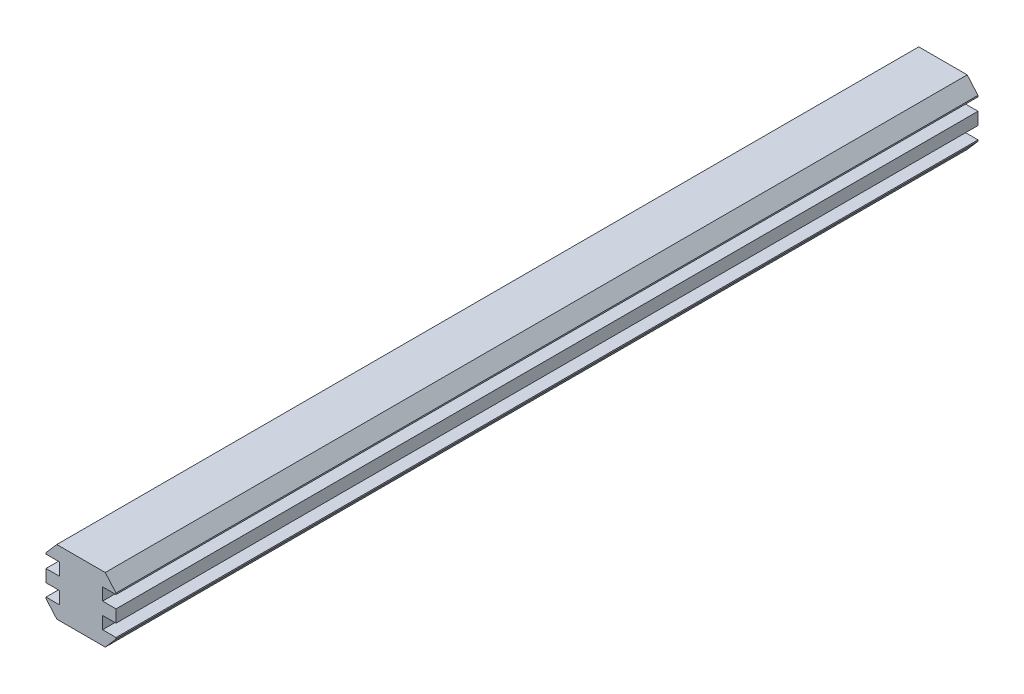
from build123d import *

# Parameters (mm, degrees)
RESSALTO_EXTRUS_O1_DEPTH = 160


with BuildPart() as part:
    # Esboço1 → Ressalto-extrusão1 (new body)
    with BuildSketch(Plane.XY):
        Polygon((-4.5, -6), (4.5, -6), (6.5, -3.7), (6.5, -3.45), (4, -3.45), (4, -1.15), (6.5, -1.15), (6.5, 1.15), (4, 1.15), (4, 3.45), (6.5, 3.45), (6.5, 3.7), (4.5, 6), (-4.5, 6), (-6.5, 3.7), (-6.5, 3.45), (-4, 3.45), (-4, 1.15), (-6.5, 1.15), (-6.5, -1.15), (-4, -1.15), (-4, -3.45), (-6.5, -3.45), (-6.5, -3.7), align=None)
    extrude(amount=RESSALTO_EXTRUS_O1_DEPTH)


solid = part.part
